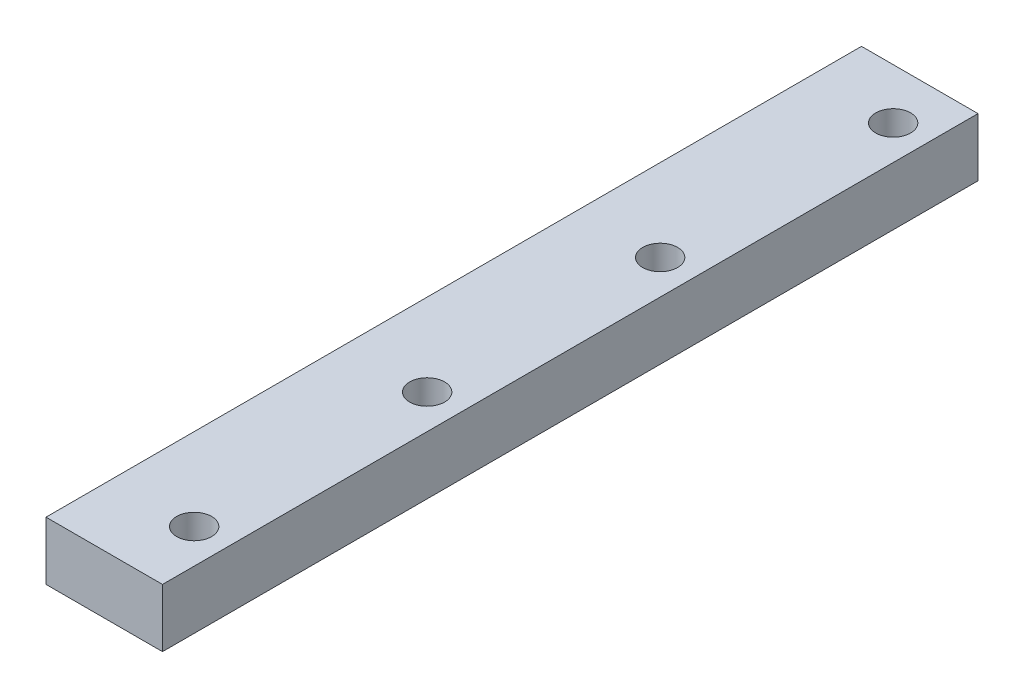
from build123d import *

# Parameters (mm, degrees)
SKETCH1_W           = 20
SKETCH1_H           = 10
BOSS_EXTRUDE1_DEPTH = 140
SKETCH2_R           = 3
CUT_EXTRUDE1_DEPTH  = 140
LPATTERN1_COUNT     = 4
LPATTERN1_PITCH     = 40


with BuildPart() as part:
    # Sketch1 → Boss-Extrude1 (new body)
    with BuildSketch(Plane.XY):
        with Locations((10, 15.187969925)):
            Rectangle(SKETCH1_W, SKETCH1_H)
    extrude(amount=BOSS_EXTRUDE1_DEPTH)

    # Sketch2 → Cut-Extrude1 (cut)
    with BuildSketch(Plane(origin=(0, 20.187969925, 0), x_dir=(1, 0, 0), z_dir=(0, 1, 0))):
        with Locations((14.108562183, -8.673667423)):
            Circle(SKETCH2_R)
    cut_extrude1 = extrude(amount=-CUT_EXTRUDE1_DEPTH, mode=Mode.SUBTRACT)

    # LPattern1: Cut-Extrude1 ×4
    with Locations(*[(0, 0, i * LPATTERN1_PITCH) for i in range(1, LPATTERN1_COUNT)]):
        add(cut_extrude1, mode=Mode.SUBTRACT)


solid = part.part
